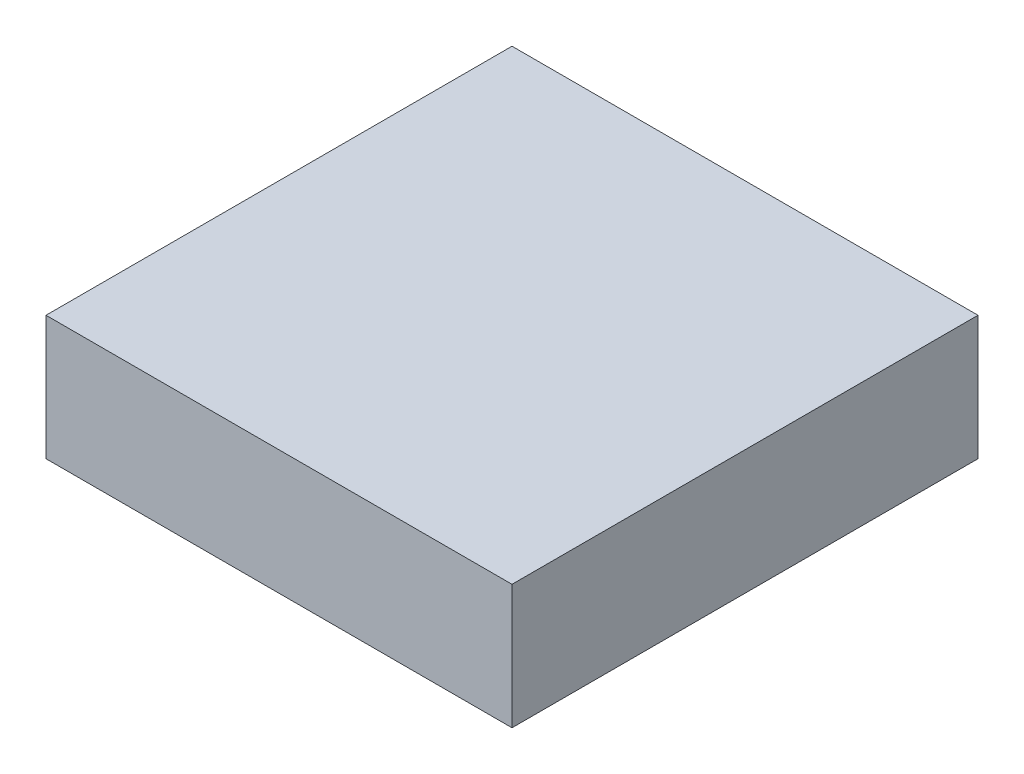
from build123d import *

# Parameters (mm, degrees)
SKETCH1_W           = 3
SKETCH1_H           = 3
BOSS_EXTRUDE1_DEPTH = 0.8


with BuildPart() as part:
    # Sketch1 → Boss-Extrude1 (new body)
    with BuildSketch(Plane(origin=(0, 0, 0), x_dir=(1, 0, 0), z_dir=(0, 1, 0))):
        with Locations((1.5, 1.5)):
            Rectangle(SKETCH1_W, SKETCH1_H)
    extrude(amount=BOSS_EXTRUDE1_DEPTH)


solid = part.part
